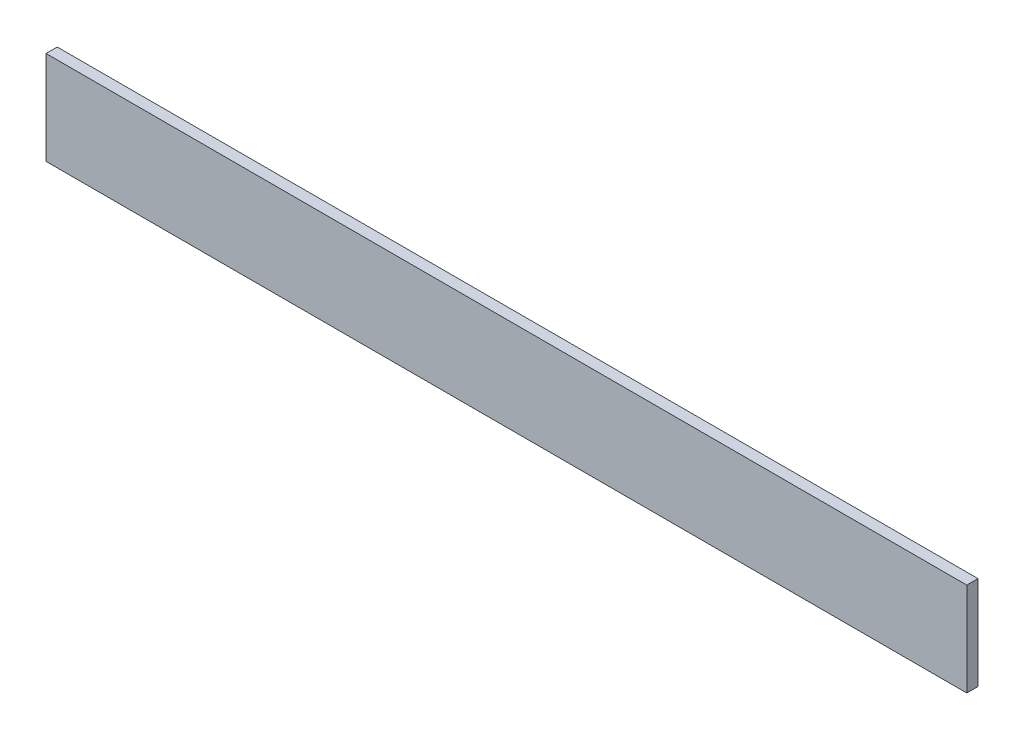
from build123d import *

# Parameters (mm, degrees)
CROQUIS1_W              = 985
CROQUIS1_H              = 100
SALIENTE_EXTRUIR1_DEPTH = 12


with BuildPart() as part:
    # Croquis1 → Saliente-Extruir1 (new body)
    with BuildSketch(Plane.XY):
        with Locations((492.5, 50)):
            Rectangle(CROQUIS1_W, CROQUIS1_H)
    extrude(amount=SALIENTE_EXTRUIR1_DEPTH)


solid = part.part
